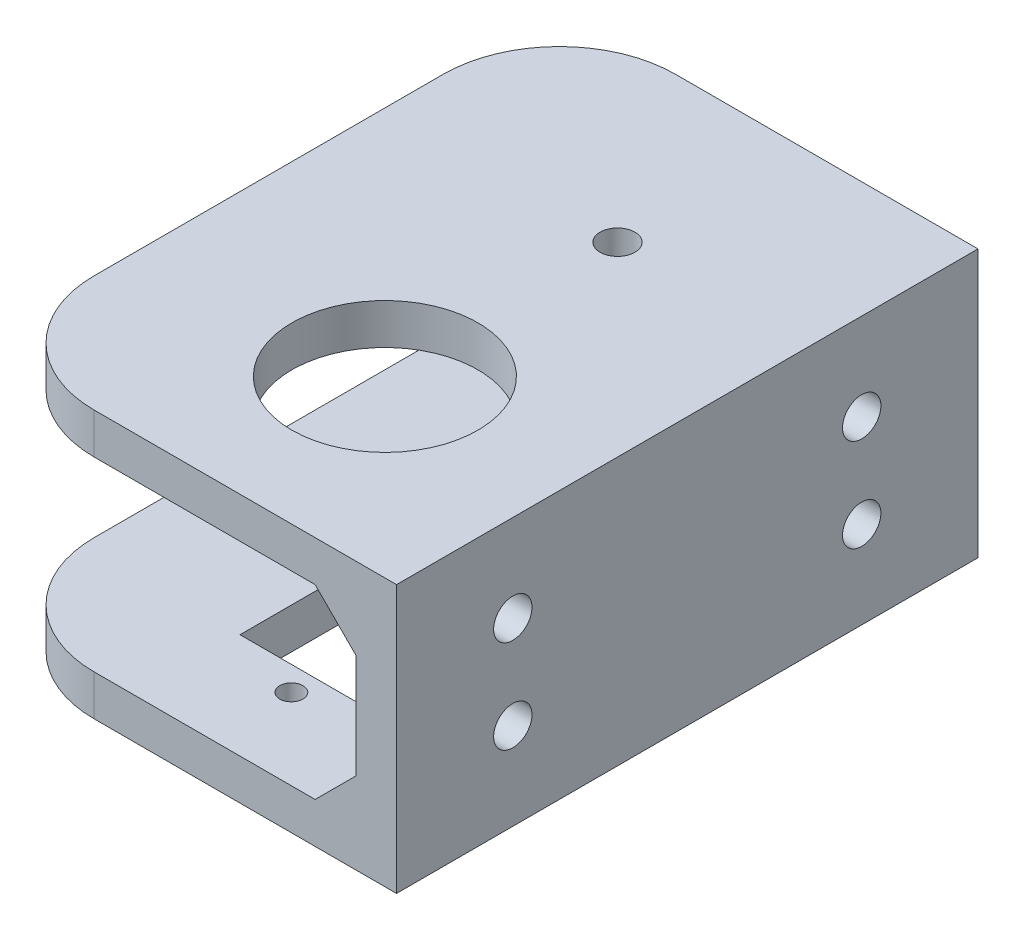
from build123d import *

# Parameters (mm, degrees)
EXTRUDE_1_DEPTH     = 50
CUT_EXTRUDE_START   = -19.5
SKETCH_2_R          = 1.5
CUT_EXTRUDE_1_DEPTH = 70
SKETCH_3_OUTSIDE_W  = 61.218
SKETCH_3_OUTSIDE_H  = 66.218
CUT_EXTRUDE_2_DEPTH = 70
SKETCH_5_R          = 1
CUT_EXTRUDE_5_DEPTH = 10
SKETCH_6_W          = 13
SKETCH_6_H          = 23.5
CUT_EXTRUDE_6_DEPTH = 10
SKETCH_7_R          = 1.65
CUT_EXTRUDE_7_DEPTH = 10
SKETCH_8_R          = 8
CUT_EXTRUDE_8_DEPTH = 10
EXTRUDE_2_DEPTH     = 3.5
EXTRUDE_3_DEPTH     = 3.5


with BuildPart() as part:
    # 草图1 → 凸台-拉伸1 (new body)
    with BuildSketch(Plane.XY):
        Polygon((-45, 11.5), (0, 11.5), (0, -11.5), (-45, -11.5), (-45, -8), (-3.5, -8), (-3.5, 8), (-45, 8), align=None)
    extrude(amount=EXTRUDE_1_DEPTH)

    # 草图2 → 切除-拉伸1 (cut)
    with BuildSketch(Plane.XZ.offset(11.5).offset(CUT_EXTRUDE_START)):
        with Locations((-16, 35)):
            Circle(SKETCH_2_R)
        with Locations((-16, 15)):
            Circle(SKETCH_2_R)
    extrude(amount=-CUT_EXTRUDE_1_DEPTH, mode=Mode.SUBTRACT)

    # 草图3 outside → 切除-拉伸2 (cut)
    with BuildSketch(Plane.XZ.offset(11.5)):
        with Locations((-22.5, 25)):
            Rectangle(SKETCH_3_OUTSIDE_W, SKETCH_3_OUTSIDE_H)
        with BuildLine():
            Line((-36, 10), (-36, 40))
            ThreePointArc((-36, 40), (-33.071067812, 47.071067812), (-26, 50))
            Line((-26, 50), (0, 50))
            Line((0, 50), (0, 0))
            Line((0, 0), (-26, 0))
            ThreePointArc((-26, 0), (-33.071067812, 2.928932188), (-36, 10))
        make_face(mode=Mode.SUBTRACT)
    extrude(amount=-CUT_EXTRUDE_2_DEPTH, mode=Mode.SUBTRACT)

    # 草图5 → 切除-拉伸5 (cut)
    with BuildSketch(Plane.XZ.offset(11.5)):
        with Locations((-16, 43.045)):
            Circle(SKETCH_5_R)
        with Locations((-16, 15.375)):
            Circle(SKETCH_5_R)
    extrude(amount=-CUT_EXTRUDE_5_DEPTH, mode=Mode.SUBTRACT)

    # 草图6 → 切除-拉伸6 (cut)
    with BuildSketch(Plane.XZ.offset(11.5)):
        with Locations((-16, 29.21)):
            Rectangle(SKETCH_6_W, SKETCH_6_H)
    extrude(amount=-CUT_EXTRUDE_6_DEPTH, mode=Mode.SUBTRACT)

    # 草图7 → 切除-拉伸7 (cut)
    with BuildSketch(Plane(origin=(0, 0, 0), x_dir=(0, 0, -1), z_dir=(1, 0, 0))):
        with Locations((-10, 4)):
            Circle(SKETCH_7_R)
        with Locations((-40, 4)):
            Circle(SKETCH_7_R)
        with Locations((-10, -4)):
            Circle(SKETCH_7_R)
        with Locations((-40, -4)):
            Circle(SKETCH_7_R)
    extrude(amount=-CUT_EXTRUDE_7_DEPTH, mode=Mode.SUBTRACT)

    # 草图8 → 切除-拉伸8 (cut)
    with BuildSketch(Plane(origin=(0, 11.5, 0), x_dir=(1, 0, 0), z_dir=(0, 1, 0))):
        with Locations((-16, -35)):
            Circle(SKETCH_8_R)
    extrude(amount=-CUT_EXTRUDE_8_DEPTH, mode=Mode.SUBTRACT)

    # 草图9 → 凸台-拉伸2 (add)
    with BuildSketch(Plane(origin=(0, 0, 0), x_dir=(-1, 0, 0), z_dir=(0, 0, -1))):
        Polygon((3.5, 4.5), (3.5, 8), (7, 8), align=None)
        Polygon((3.5, -8), (7, -8), (3.5, -4.5), align=None)
    extrude(amount=-EXTRUDE_2_DEPTH)

    # 草图10 → 凸台-拉伸3 (add)
    with BuildSketch(Plane.XY.offset(50)):
        Polygon((-3.5, 8), (-7, 8), (-3.5, 4.5), align=None)
        Polygon((-3.5, -8), (-3.5, -4.5), (-7, -8), align=None)
    extrude(amount=-EXTRUDE_3_DEPTH)


solid = part.part
